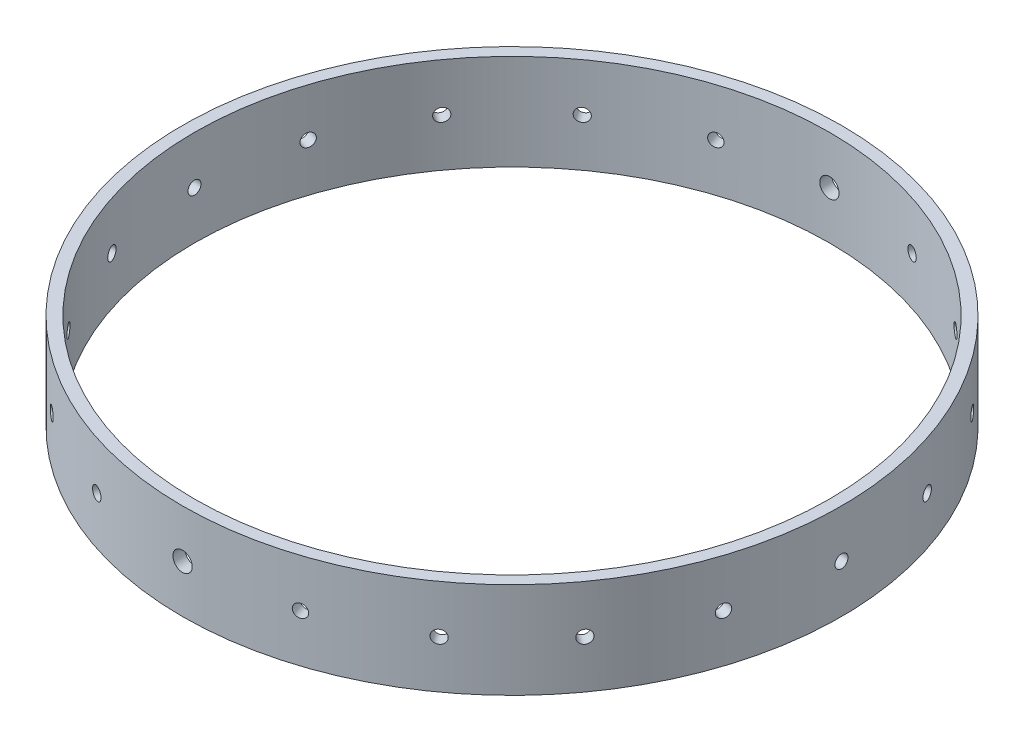
from build123d import *

# Parameters (mm, degrees)
SKETCH1_R           = 87.3125
SKETCH1_R_2         = 84.1375
BOSS_EXTRUDE1_DEPTH = 25.4
CIRPATTERN1_COUNT   = 2
CIRPATTERN2_COUNT   = 20


with BuildPart() as part:
    # Sketch1 → Boss-Extrude1 (new body)
    with BuildSketch(Plane(origin=(0, 0, 0), x_dir=(1, 0, 0), z_dir=(0, 1, 0))):
        Circle(SKETCH1_R)
        Circle(SKETCH1_R_2, mode=Mode.SUBTRACT)
    extrude(amount=BOSS_EXTRUDE1_DEPTH)

    # Sketch6 → 1_4-20 Tapped Hole1 (revolve, cut)
    with BuildSketch(Plane(origin=(0, 12.7, 87.3125), x_dir=(0, -1, 0), z_dir=(1, 0, 0))):
        Polygon((0, 0), (0, 14.233816902), (2.5527, 12.7), (2.5527, 0), align=None)
    f_1_4_20_tapped_hole1 = revolve(axis=Axis((0, 12.7, 93.6625), (0, 0, -1)), mode=Mode.SUBTRACT)

    # Sketch9 → 8-32 Tapped Hole1 (revolve, cut)
    with BuildSketch(Plane(origin=(87.3125, 12.7, 0), x_dir=(0, 0, -1), z_dir=(0, 1, 0))):
        Polygon((0, 0), (0, 13.737806461), (1.7272, 12.7), (1.7272, 0), align=None)
    f_8_32_tapped_hole1 = revolve(axis=Axis((93.6625, 12.7, 0), (-1, 0, 0)), mode=Mode.SUBTRACT)

    # CirPattern1: 1_4-20 Tapped Hole1 ×2 about axis
    cirpattern1_axis = Axis((0, 25.4, 0), (0, -1, 0))
    for i in range(1, CIRPATTERN1_COUNT):
        add(f_1_4_20_tapped_hole1.rotate(cirpattern1_axis, i * 360 / CIRPATTERN1_COUNT), mode=Mode.SUBTRACT)

    # CirPattern2: 8-32 Tapped Hole1 ×20 about axis, 2 skipped
    cirpattern2_axis = Axis((0, 25.4, 0), (0, -1, 0))
    add([f_8_32_tapped_hole1.rotate(cirpattern2_axis, i * 360 / CIRPATTERN2_COUNT) for i in range(1, CIRPATTERN2_COUNT) if i not in (5, 15)], mode=Mode.SUBTRACT)


solid = part.part
